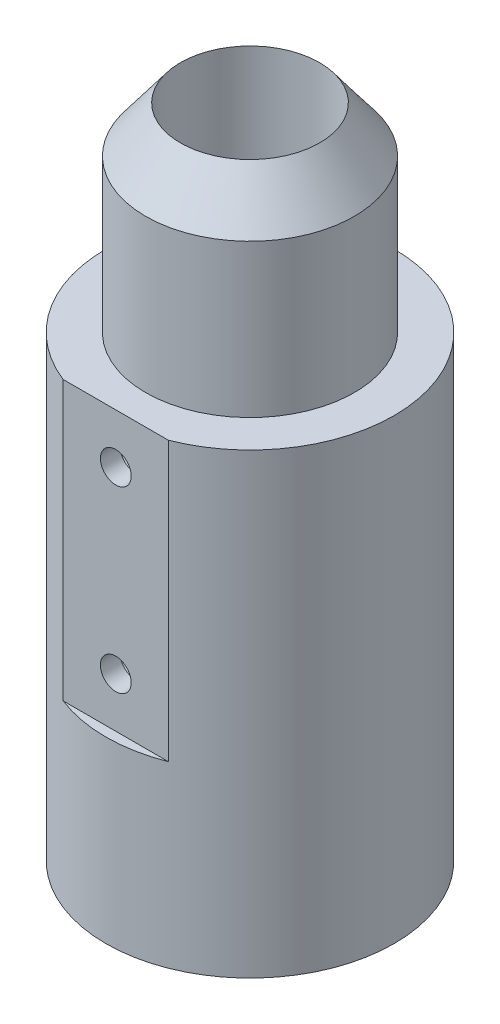
from build123d import *

# Parameters (mm, degrees)
SKETCH1_R                        = 23.01875
SKETCH1_R_2                      = 11.1125
BOSS_EXTRUDE1_DEPTH              = 76.2
SKETCH2_R                        = 16.66875
SKETCH2_R_2                      = 11.1125
BOSS_EXTRUDE2_DEPTH              = 31.75
CUT_EXTRUDE1_START               = -44.45
CUT_EXTRUDE1_DEPTH               = 44.45
F_10_0_1935_DIAMETER_HOLE1_D     = 4.9149
F_10_0_1935_DIAMETER_HOLE1_DEPTH = 3.175
F_10_0_1935_DIAMETER_HOLE1_TIP   = 1.476584928


with BuildPart() as part:
    # Sketch1 → Boss-Extrude1 (new body)
    with BuildSketch(Plane(origin=(0, 0, 0), x_dir=(1, 0, 0), z_dir=(0, 1, 0))):
        Circle(SKETCH1_R)
        Circle(SKETCH1_R_2, mode=Mode.SUBTRACT)
    extrude(amount=BOSS_EXTRUDE1_DEPTH)

    # Sketch2 → Boss-Extrude2 (add)
    with BuildSketch(Plane(origin=(0, 76.2, 0), x_dir=(1, 0, 0), z_dir=(0, 1, 0))):
        Circle(SKETCH2_R)
        Circle(SKETCH2_R_2, mode=Mode.SUBTRACT)
    extrude(amount=BOSS_EXTRUDE2_DEPTH)

    # Sketch3 → Cut-Revolve1 (revolve, cut)
    with BuildSketch(Plane(origin=(0, 0, 0), x_dir=(0, 0, -1), z_dir=(1, 0, 0))):
        Polygon((16.66875, 107.95), (16.66875, 100.57660721), (11.1125, 107.95), align=None)
    revolve(axis=Axis((0, 107.95, 0), (0, 1, 0)), mode=Mode.SUBTRACT)

    # Sketch4 → Cut-Extrude1 (cut)
    with BuildSketch(Plane(origin=(0, 76.2, 0), x_dir=(1, 0, 0), z_dir=(0, 1, 0)).offset(CUT_EXTRUDE1_START)):
        with BuildLine():
            Line((8.400260413, -21.43125), (-8.400260413, -21.43125))
            ThreePointArc((-8.400260413, -21.43125), (0, -23.01875), (8.400260413, -21.43125))
        make_face()
    extrude(amount=CUT_EXTRUDE1_DEPTH, mode=Mode.SUBTRACT)

    # Sketch8 → Cut-Revolve4 (revolve, cut)
    with BuildSketch(Plane.XY):
        with BuildLine():
            Line((0, 0), (-3.369464108, 0))
            ThreePointArc((-3.369464108, 0), (-13.321537524, 0.798864496), (-23.01875, 3.175))
            Line((-23.01875, 3.175), (-23.01875, -4.469484217))
            Line((-23.01875, -4.469484217), (0, -4.469484217))
            Line((0, -4.469484217), (0, 0))
        make_face()
    revolve(axis=Axis((0, 0, 0), (0, 1, 0)), mode=Mode.SUBTRACT)

    # 10 _0.1935_ Diameter Hole1
    with Locations(Plane.XY.offset(21.43125)):
        with Locations((0, 68.2625), (0, 39.6875)):
            Hole(F_10_0_1935_DIAMETER_HOLE1_D / 2, depth=F_10_0_1935_DIAMETER_HOLE1_DEPTH)
            with Locations((0, 0, -(F_10_0_1935_DIAMETER_HOLE1_DEPTH + F_10_0_1935_DIAMETER_HOLE1_TIP / 2))):  # 118° drill point
                Cone(0, F_10_0_1935_DIAMETER_HOLE1_D / 2, F_10_0_1935_DIAMETER_HOLE1_TIP, mode=Mode.SUBTRACT)


solid = part.part
